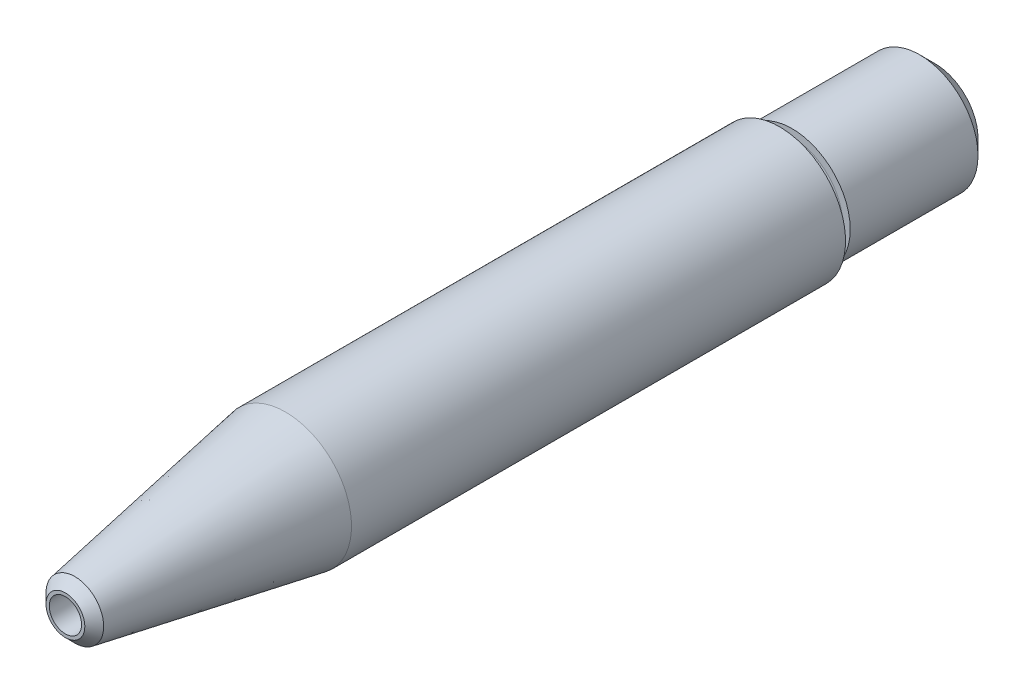
from build123d import *

# Parameters (mm, degrees)
SKETCH1_R                       = 5.3975
BOSS_EXTRUDE1_DEPTH             = 71.12
SKETCH8_R                       = 1.3208
CUT_EXTRUDE1_DEPTH              = 72.12
SKETCH10_R                      = 5.3975
SKETCH10_R_2                    = 4.7625
CUT_EXTRUDE2_DEPTH              = 12.7
F_1_4_0_25_DIAMETER_HOLE1_D     = 6.35
F_1_4_0_25_DIAMETER_HOLE1_DEPTH = 60.96
F_1_4_0_25_DIAMETER_HOLE1_TIP   = 1.907732465
CHAMFER1_SIZE2                  = 0.635
CHAMFER1_SIZE                   = 0.782829938


with BuildPart() as part:
    # Sketch1 → Boss-Extrude1 (new body)
    with BuildSketch(Plane.XY):
        Circle(SKETCH1_R)
    extrude(amount=BOSS_EXTRUDE1_DEPTH)

    # Sketch7 → Cut-Revolve1 (revolve, cut)
    with BuildSketch(Plane(origin=(0, 0, 0), x_dir=(1, 0, 0), z_dir=(0, 1, 0))):
        Polygon((5.3975, -71.12), (5.3975, -53.113680223), (2.2225, -71.12), align=None)
    revolve(axis=Axis((0, 0, -47.573976859), (0, 0, 1)), mode=Mode.SUBTRACT)

    # Sketch8 → Cut-Extrude1 (cut, through all)
    with BuildSketch(Plane.XY.offset(71.12)):
        Circle(SKETCH8_R)
    extrude(amount=-CUT_EXTRUDE1_DEPTH, mode=Mode.SUBTRACT)

    # Sketch10 → Cut-Extrude2 (cut)
    with BuildSketch(Plane(origin=(0, 0, 0), x_dir=(-1, 0, 0), z_dir=(0, 0, -1))):
        Circle(SKETCH10_R)
        Circle(SKETCH10_R_2, mode=Mode.SUBTRACT)
    extrude(amount=-CUT_EXTRUDE2_DEPTH, mode=Mode.SUBTRACT)

    # 1/4 (0.25) Diameter Hole1
    with Locations(Plane(origin=(0, 0, 0), x_dir=(-1, 0, 0), z_dir=(0, 0, -1))):
        with Locations((0, 0)):
            Hole(F_1_4_0_25_DIAMETER_HOLE1_D / 2, depth=F_1_4_0_25_DIAMETER_HOLE1_DEPTH)
            with Locations((0, 0, -(F_1_4_0_25_DIAMETER_HOLE1_DEPTH + F_1_4_0_25_DIAMETER_HOLE1_TIP / 2))):  # 118° drill point
                Cone(0, F_1_4_0_25_DIAMETER_HOLE1_D / 2, F_1_4_0_25_DIAMETER_HOLE1_TIP, mode=Mode.SUBTRACT)

    # Sketch18 → Cut-Revolve2 (revolve, cut)
    with BuildSketch(Plane(origin=(0, 0, 0), x_dir=(1, 0, 0), z_dir=(0, 1, 0))):
        with BuildLine():
            Line((4.7625, -12.7), (4.1656, -12.7))
            ThreePointArc((4.1656, -12.7), (3.6576, -12.192), (4.1656, -11.684))
            Line((4.1656, -11.684), (4.7625, -11.684))
            Line((4.7625, -11.684), (4.7625, -12.7))
        make_face()
    revolve(axis=Axis((0, 0, 0.466216552), (0, 0, -1)), mode=Mode.SUBTRACT)

    # Sketch20 → Cut-Revolve3 (revolve, cut)
    with BuildSketch(Plane(origin=(0, 0, 0), x_dir=(1, 0, 0), z_dir=(0, 1, 0))):
        Polygon((4.7625, 0), (4.7625, -1.2319), (3.5306, 0), align=None)
    revolve(axis=Axis((0, 0, 0.466216552), (0, 0, -1)), mode=Mode.SUBTRACT)

    # Chamfer1
    chamfer1_edges = [part.edges().sort_by_distance(p)[0] for p in [
        (-2.2225, 0, 71.12),
    ]]
    chamfer(chamfer1_edges, length=CHAMFER1_SIZE, length2=CHAMFER1_SIZE2)


solid = part.part
